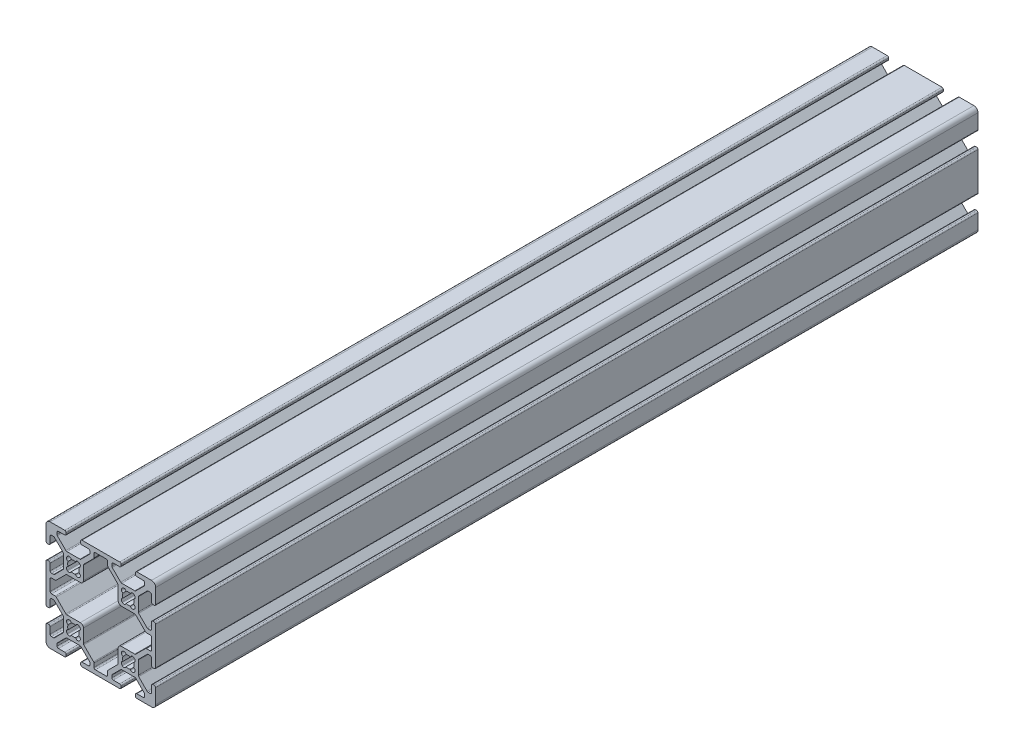
from build123d import *

# Parameters (mm, degrees)
EXTRUDE1_DEPTH = 300


with BuildPart() as part:
    # Sketch1 → Extrude1 (new body)
    with BuildSketch(Plane.XY):
        with BuildLine():
            Line((-22.383919339, -3.655), (-17.616080661, -3.655))
            ThreePointArc((-17.616080661, -3.655), (-17.421677478, -3.693669197), (-17.256870417, -3.803789755))
            Line((-17.256870417, -3.803789755), (-14.153789755, -6.906870417))
            ThreePointArc((-14.153789755, -6.906870417), (-14.043669197, -7.071677478), (-14.005, -7.266080661))
            Line((-14.005, -7.266080661), (-14.005, -7.992))
            ThreePointArc((-14.005, -7.992), (-14.153789755, -8.351210245), (-14.513, -8.5))
            Line((-14.513, -8.5), (-16.862, -8.5))
            ThreePointArc((-16.862, -8.5), (-17.221210245, -8.648789755), (-17.37, -9.008))
            Line((-17.37, -9.008), (-17.37, -9.492))
            ThreePointArc((-17.37, -9.492), (-17.221210245, -9.851210245), (-16.862, -10))
            Line((-16.862, -10), (-3.138, -10))
            ThreePointArc((-3.138, -10), (-2.778789755, -9.851210245), (-2.63, -9.492))
            Line((-2.63, -9.492), (-2.63, -9.008))
            ThreePointArc((-2.63, -9.008), (-2.778789755, -8.648789755), (-3.138, -8.5))
            Line((-3.138, -8.5), (-5.487, -8.5))
            ThreePointArc((-5.487, -8.5), (-5.846210245, -8.351210245), (-5.995, -7.992))
            Line((-5.995, -7.992), (-5.995, -7.266080661))
            ThreePointArc((-5.995, -7.266080661), (-5.956330803, -7.071677478), (-5.846210245, -6.906870417))
            Line((-5.846210245, -6.906870417), (-2.743129583, -3.803789755))
            ThreePointArc((-2.743129583, -3.803789755), (-2.578322522, -3.693669197), (-2.383919339, -3.655))
            Line((-2.383919339, -3.655), (2.383919339, -3.655))
            ThreePointArc((2.383919339, -3.655), (2.578322522, -3.693669197), (2.743129583, -3.803789755))
            Line((2.743129583, -3.803789755), (5.846210245, -6.906870417))
            ThreePointArc((5.846210245, -6.906870417), (5.956330803, -7.071677478), (5.995, -7.266080661))
            Line((5.995, -7.266080661), (5.995, -7.992))
            ThreePointArc((5.995, -7.992), (5.846210245, -8.351210245), (5.487, -8.5))
            Line((5.487, -8.5), (3.138, -8.5))
            ThreePointArc((3.138, -8.5), (2.778789755, -8.648789755), (2.63, -9.008))
            Line((2.63, -9.008), (2.63, -9.492))
            ThreePointArc((2.63, -9.492), (2.778789755, -9.851210245), (3.138, -10))
            Line((3.138, -10), (8.5, -10))
            ThreePointArc((8.5, -10), (9.560660172, -9.560660172), (10, -8.5))
            Line((10, -8.5), (10, -3.138))
            ThreePointArc((10, -3.138), (9.851210245, -2.778789755), (9.492, -2.63))
            Line((9.492, -2.63), (9.008, -2.63))
            ThreePointArc((9.008, -2.63), (8.648789755, -2.778789755), (8.5, -3.138))
            Line((8.5, -3.138), (8.5, -5.487))
            ThreePointArc((8.5, -5.487), (8.351210245, -5.846210245), (7.992, -5.995))
            Line((7.992, -5.995), (7.266080661, -5.995))
            ThreePointArc((7.266080661, -5.995), (7.071677478, -5.956330803), (6.906870417, -5.846210245))
            Line((6.906870417, -5.846210245), (3.803789755, -2.743129583))
            ThreePointArc((3.803789755, -2.743129583), (3.693669197, -2.578322522), (3.655, -2.383919339))
            Line((3.655, -2.383919339), (3.655, 2.383919339))
            ThreePointArc((3.655, 2.383919339), (3.693669197, 2.578322522), (3.803789755, 2.743129583))
            Line((3.803789755, 2.743129583), (6.906870417, 5.846210245))
            ThreePointArc((6.906870417, 5.846210245), (7.071677478, 5.956330803), (7.266080661, 5.995))
            Line((7.266080661, 5.995), (7.992, 5.995))
            ThreePointArc((7.992, 5.995), (8.351210245, 5.846210245), (8.5, 5.487))
            Line((8.5, 5.487), (8.5, 3.138))
            ThreePointArc((8.5, 3.138), (8.648789755, 2.778789755), (9.008, 2.63))
            Line((9.008, 2.63), (9.492, 2.63))
            ThreePointArc((9.492, 2.63), (9.851210245, 2.778789755), (10, 3.138))
            Line((10, 3.138), (10, 16.862))
            ThreePointArc((10, 16.862), (9.851210245, 17.221210245), (9.492, 17.37))
            Line((9.492, 17.37), (9.008, 17.37))
            ThreePointArc((9.008, 17.37), (8.648789755, 17.221210245), (8.5, 16.862))
            Line((8.5, 16.862), (8.5, 14.513))
            ThreePointArc((8.5, 14.513), (8.351210245, 14.153789755), (7.992, 14.005))
            Line((7.992, 14.005), (7.266080661, 14.005))
            ThreePointArc((7.266080661, 14.005), (7.071677478, 14.043669197), (6.906870417, 14.153789755))
            Line((6.906870417, 14.153789755), (3.803789755, 17.256870417))
            ThreePointArc((3.803789755, 17.256870417), (3.693669197, 17.421677478), (3.655, 17.616080661))
            Line((3.655, 17.616080661), (3.655, 22.383919339))
            ThreePointArc((3.655, 22.383919339), (3.693669197, 22.578322522), (3.803789755, 22.743129583))
            Line((3.803789755, 22.743129583), (6.906870417, 25.846210245))
            ThreePointArc((6.906870417, 25.846210245), (7.071677478, 25.956330803), (7.266080661, 25.995))
            Line((7.266080661, 25.995), (7.992, 25.995))
            ThreePointArc((7.992, 25.995), (8.351210245, 25.846210245), (8.5, 25.487))
            Line((8.5, 25.487), (8.5, 23.138))
            ThreePointArc((8.5, 23.138), (8.648789755, 22.778789755), (9.008, 22.63))
            Line((9.008, 22.63), (9.492, 22.63))
            ThreePointArc((9.492, 22.63), (9.851210245, 22.778789755), (10, 23.138))
            Line((10, 23.138), (10, 28.5))
            ThreePointArc((10, 28.5), (9.560660172, 29.560660172), (8.5, 30))
            Line((8.5, 30), (3.138, 30))
            ThreePointArc((3.138, 30), (2.778789755, 29.851210245), (2.63, 29.492))
            Line((2.63, 29.492), (2.63, 29.008))
            ThreePointArc((2.63, 29.008), (2.778789755, 28.648789755), (3.138, 28.5))
            Line((3.138, 28.5), (5.487, 28.5))
            ThreePointArc((5.487, 28.5), (5.846210245, 28.351210245), (5.995, 27.992))
            Line((5.995, 27.992), (5.995, 27.266080661))
            ThreePointArc((5.995, 27.266080661), (5.956330803, 27.071677478), (5.846210245, 26.906870417))
            Line((5.846210245, 26.906870417), (2.743129583, 23.803789755))
            ThreePointArc((2.743129583, 23.803789755), (2.578322522, 23.693669197), (2.383919339, 23.655))
            Line((2.383919339, 23.655), (-2.383919339, 23.655))
            ThreePointArc((-2.383919339, 23.655), (-2.578322522, 23.693669197), (-2.743129583, 23.803789755))
            Line((-2.743129583, 23.803789755), (-5.846210245, 26.906870417))
            ThreePointArc((-5.846210245, 26.906870417), (-5.956330803, 27.071677478), (-5.995, 27.266080661))
            Line((-5.995, 27.266080661), (-5.995, 27.992))
            ThreePointArc((-5.995, 27.992), (-5.846210245, 28.351210245), (-5.487, 28.5))
            Line((-5.487, 28.5), (-3.138, 28.5))
            ThreePointArc((-3.138, 28.5), (-2.778789755, 28.648789755), (-2.63, 29.008))
            Line((-2.63, 29.008), (-2.63, 29.492))
            ThreePointArc((-2.63, 29.492), (-2.778789755, 29.851210245), (-3.138, 30))
            Line((-3.138, 30), (-16.862, 30))
            ThreePointArc((-16.862, 30), (-17.221210245, 29.851210245), (-17.37, 29.492))
            Line((-17.37, 29.492), (-17.37, 29.008))
            ThreePointArc((-17.37, 29.008), (-17.221210245, 28.648789755), (-16.862, 28.5))
            Line((-16.862, 28.5), (-14.513, 28.5))
            ThreePointArc((-14.513, 28.5), (-14.153789755, 28.351210245), (-14.005, 27.992))
            Line((-14.005, 27.992), (-14.005, 27.266080661))
            ThreePointArc((-14.005, 27.266080661), (-14.043669197, 27.071677478), (-14.153789755, 26.906870417))
            Line((-14.153789755, 26.906870417), (-17.256870417, 23.803789755))
            ThreePointArc((-17.256870417, 23.803789755), (-17.421677478, 23.693669197), (-17.616080661, 23.655))
            Line((-17.616080661, 23.655), (-22.383919339, 23.655))
            ThreePointArc((-22.383919339, 23.655), (-22.578322522, 23.693669197), (-22.743129583, 23.803789755))
            Line((-22.743129583, 23.803789755), (-25.846210245, 26.906870417))
            ThreePointArc((-25.846210245, 26.906870417), (-25.956330803, 27.071677478), (-25.995, 27.266080661))
            Line((-25.995, 27.266080661), (-25.995, 27.992))
            ThreePointArc((-25.995, 27.992), (-25.846210245, 28.351210245), (-25.487, 28.5))
            Line((-25.487, 28.5), (-23.138, 28.5))
            ThreePointArc((-23.138, 28.5), (-22.778789755, 28.648789755), (-22.63, 29.008))
            Line((-22.63, 29.008), (-22.63, 29.492))
            ThreePointArc((-22.63, 29.492), (-22.778789755, 29.851210245), (-23.138, 30))
            Line((-23.138, 30), (-28.5, 30))
            ThreePointArc((-28.5, 30), (-29.560660172, 29.560660172), (-30, 28.5))
            Line((-30, 28.5), (-30, 23.138))
            ThreePointArc((-30, 23.138), (-29.851210245, 22.778789755), (-29.492, 22.63))
            Line((-29.492, 22.63), (-29.008, 22.63))
            ThreePointArc((-29.008, 22.63), (-28.648789755, 22.778789755), (-28.5, 23.138))
            Line((-28.5, 23.138), (-28.5, 25.487))
            ThreePointArc((-28.5, 25.487), (-28.351210245, 25.846210245), (-27.992, 25.995))
            Line((-27.992, 25.995), (-27.266080661, 25.995))
            ThreePointArc((-27.266080661, 25.995), (-27.071677478, 25.956330803), (-26.906870417, 25.846210245))
            Line((-26.906870417, 25.846210245), (-23.803789755, 22.743129583))
            ThreePointArc((-23.803789755, 22.743129583), (-23.693669197, 22.578322522), (-23.655, 22.383919339))
            Line((-23.655, 22.383919339), (-23.655, 17.616080661))
            ThreePointArc((-23.655, 17.616080661), (-23.693669197, 17.421677478), (-23.803789755, 17.256870417))
            Line((-23.803789755, 17.256870417), (-26.906870417, 14.153789755))
            ThreePointArc((-26.906870417, 14.153789755), (-27.071677478, 14.043669197), (-27.266080661, 14.005))
            Line((-27.266080661, 14.005), (-27.992, 14.005))
            ThreePointArc((-27.992, 14.005), (-28.351210245, 14.153789755), (-28.5, 14.513))
            Line((-28.5, 14.513), (-28.5, 16.862))
            ThreePointArc((-28.5, 16.862), (-28.648789755, 17.221210245), (-29.008, 17.37))
            Line((-29.008, 17.37), (-29.492, 17.37))
            ThreePointArc((-29.492, 17.37), (-29.851210245, 17.221210245), (-30, 16.862))
            Line((-30, 16.862), (-30, 3.138))
            ThreePointArc((-30, 3.138), (-29.851210245, 2.778789755), (-29.492, 2.63))
            Line((-29.492, 2.63), (-29.008, 2.63))
            ThreePointArc((-29.008, 2.63), (-28.648789755, 2.778789755), (-28.5, 3.138))
            Line((-28.5, 3.138), (-28.5, 5.487))
            ThreePointArc((-28.5, 5.487), (-28.351210245, 5.846210245), (-27.992, 5.995))
            Line((-27.992, 5.995), (-27.266080661, 5.995))
            ThreePointArc((-27.266080661, 5.995), (-27.071677478, 5.956330803), (-26.906870417, 5.846210245))
            Line((-26.906870417, 5.846210245), (-23.803789755, 2.743129583))
            ThreePointArc((-23.803789755, 2.743129583), (-23.693669197, 2.578322522), (-23.655, 2.383919339))
            Line((-23.655, 2.383919339), (-23.655, -2.383919339))
            ThreePointArc((-23.655, -2.383919339), (-23.693669197, -2.578322522), (-23.803789755, -2.743129583))
            Line((-23.803789755, -2.743129583), (-26.906870417, -5.846210245))
            ThreePointArc((-26.906870417, -5.846210245), (-27.071677478, -5.956330803), (-27.266080661, -5.995))
            Line((-27.266080661, -5.995), (-27.992, -5.995))
            ThreePointArc((-27.992, -5.995), (-28.351210245, -5.846210245), (-28.5, -5.487))
            Line((-28.5, -5.487), (-28.5, -3.138))
            ThreePointArc((-28.5, -3.138), (-28.648789755, -2.778789755), (-29.008, -2.63))
            Line((-29.008, -2.63), (-29.492, -2.63))
            ThreePointArc((-29.492, -2.63), (-29.851210245, -2.778789755), (-30, -3.138))
            Line((-30, -3.138), (-30, -8.5))
            ThreePointArc((-30, -8.5), (-29.560660172, -9.560660172), (-28.5, -10))
            Line((-28.5, -10), (-23.138, -10))
            ThreePointArc((-23.138, -10), (-22.778789755, -9.851210245), (-22.63, -9.492))
            Line((-22.63, -9.492), (-22.63, -9.008))
            ThreePointArc((-22.63, -9.008), (-22.778789755, -8.648789755), (-23.138, -8.5))
            Line((-23.138, -8.5), (-25.487, -8.5))
            ThreePointArc((-25.487, -8.5), (-25.846210245, -8.351210245), (-25.995, -7.992))
            Line((-25.995, -7.992), (-25.995, -7.266080661))
            ThreePointArc((-25.995, -7.266080661), (-25.956330803, -7.071677478), (-25.846210245, -6.906870417))
            Line((-25.846210245, -6.906870417), (-22.743129583, -3.803789755))
            ThreePointArc((-22.743129583, -3.803789755), (-22.578322522, -3.693669197), (-22.383919339, -3.655))
        make_face()
        with BuildLine():
            Line((-2.124900844, 17.695494034), (-2.304505966, 17.875099156))
            ThreePointArc((-2.304505966, 17.875099156), (-2.505938017, 18.643532189), (-1.935133506, 19.196023282))
            ThreePointArc((-1.935133506, 19.196023282), (-2.0955, 20), (-1.935133506, 20.803976718))
            ThreePointArc((-1.935133506, 20.803976718), (-2.505938017, 21.356467811), (-2.304505966, 22.124900844))
            Line((-2.304505966, 22.124900844), (-2.124900844, 22.304505966))
            ThreePointArc((-2.124900844, 22.304505966), (-1.356467811, 22.505938017), (-0.803976718, 21.935133506))
            ThreePointArc((-0.803976718, 21.935133506), (0, 22.0955), (0.803976718, 21.935133506))
            ThreePointArc((0.803976718, 21.935133506), (1.356467811, 22.505938017), (2.124900844, 22.304505966))
            Line((2.124900844, 22.304505966), (2.304505966, 22.124900844))
            ThreePointArc((2.304505966, 22.124900844), (2.505938017, 21.356467811), (1.935133506, 20.803976718))
            ThreePointArc((1.935133506, 20.803976718), (2.0955, 20), (1.935133506, 19.196023282))
            ThreePointArc((1.935133506, 19.196023282), (2.505938017, 18.643532189), (2.304505966, 17.875099156))
            Line((2.304505966, 17.875099156), (2.124900844, 17.695494034))
            ThreePointArc((2.124900844, 17.695494034), (1.356467811, 17.494061983), (0.803976718, 18.064866494))
            ThreePointArc((0.803976718, 18.064866494), (0, 17.9045), (-0.803976718, 18.064866494))
            ThreePointArc((-0.803976718, 18.064866494), (-1.356467811, 17.494061983), (-2.124900844, 17.695494034))
        make_face(mode=Mode.SUBTRACT)
        with BuildLine():
            Line((-22.124900844, 17.695494034), (-22.304505966, 17.875099156))
            ThreePointArc((-22.304505966, 17.875099156), (-22.505938017, 18.643532189), (-21.935133506, 19.196023282))
            ThreePointArc((-21.935133506, 19.196023282), (-22.0955, 20), (-21.935133506, 20.803976718))
            ThreePointArc((-21.935133506, 20.803976718), (-22.505938017, 21.356467811), (-22.304505966, 22.124900844))
            Line((-22.304505966, 22.124900844), (-22.124900844, 22.304505966))
            ThreePointArc((-22.124900844, 22.304505966), (-21.356467811, 22.505938017), (-20.803976718, 21.935133506))
            ThreePointArc((-20.803976718, 21.935133506), (-20, 22.0955), (-19.196023282, 21.935133506))
            ThreePointArc((-19.196023282, 21.935133506), (-18.643532189, 22.505938017), (-17.875099156, 22.304505966))
            Line((-17.875099156, 22.304505966), (-17.695494034, 22.124900844))
            ThreePointArc((-17.695494034, 22.124900844), (-17.494061983, 21.356467811), (-18.064866494, 20.803976718))
            ThreePointArc((-18.064866494, 20.803976718), (-17.9045, 20), (-18.064866494, 19.196023282))
            ThreePointArc((-18.064866494, 19.196023282), (-17.494061983, 18.643532189), (-17.695494034, 17.875099156))
            Line((-17.695494034, 17.875099156), (-17.875099156, 17.695494034))
            ThreePointArc((-17.875099156, 17.695494034), (-18.643532189, 17.494061983), (-19.196023282, 18.064866494))
            ThreePointArc((-19.196023282, 18.064866494), (-20, 17.9045), (-20.803976718, 18.064866494))
            ThreePointArc((-20.803976718, 18.064866494), (-21.356467811, 17.494061983), (-22.124900844, 17.695494034))
        make_face(mode=Mode.SUBTRACT)
        with BuildLine():
            Line((-2.124900844, -2.304505966), (-2.304505966, -2.124900844))
            ThreePointArc((-2.304505966, -2.124900844), (-2.505938017, -1.356467811), (-1.935133506, -0.803976718))
            ThreePointArc((-1.935133506, -0.803976718), (-2.0955, 0), (-1.935133506, 0.803976718))
            ThreePointArc((-1.935133506, 0.803976718), (-2.505938017, 1.356467811), (-2.304505966, 2.124900844))
            Line((-2.304505966, 2.124900844), (-2.124900844, 2.304505966))
            ThreePointArc((-2.124900844, 2.304505966), (-1.356467811, 2.505938017), (-0.803976718, 1.935133506))
            ThreePointArc((-0.803976718, 1.935133506), (0, 2.0955), (0.803976718, 1.935133506))
            ThreePointArc((0.803976718, 1.935133506), (1.356467811, 2.505938017), (2.124900844, 2.304505966))
            Line((2.124900844, 2.304505966), (2.304505966, 2.124900844))
            ThreePointArc((2.304505966, 2.124900844), (2.505938017, 1.356467811), (1.935133506, 0.803976718))
            ThreePointArc((1.935133506, 0.803976718), (2.0955, 0), (1.935133506, -0.803976718))
            ThreePointArc((1.935133506, -0.803976718), (2.505938017, -1.356467811), (2.304505966, -2.124900844))
            Line((2.304505966, -2.124900844), (2.124900844, -2.304505966))
            ThreePointArc((2.124900844, -2.304505966), (1.356467811, -2.505938017), (0.803976718, -1.935133506))
            ThreePointArc((0.803976718, -1.935133506), (0, -2.0955), (-0.803976718, -1.935133506))
            ThreePointArc((-0.803976718, -1.935133506), (-1.356467811, -2.505938017), (-2.124900844, -2.304505966))
        make_face(mode=Mode.SUBTRACT)
        with BuildLine():
            Line((-12.505, -7.992), (-12.505, -6.644760318))
            ThreePointArc((-12.505, -6.644760318), (-12.543669197, -6.450357134), (-12.653789755, -6.285550073))
            Line((-12.653789755, -6.285550073), (-16.196210245, -2.743129583))
            ThreePointArc((-16.196210245, -2.743129583), (-16.306330803, -2.578322522), (-16.345, -2.383919339))
            Line((-16.345, -2.383919339), (-16.345, 2.512))
            ThreePointArc((-16.345, 2.512), (-16.679776949, 3.320223051), (-17.488, 3.655))
            Line((-17.488, 3.655), (-22.383919339, 3.655))
            ThreePointArc((-22.383919339, 3.655), (-22.578322522, 3.693669197), (-22.743129583, 3.803789755))
            Line((-22.743129583, 3.803789755), (-26.285550073, 7.346210245))
            ThreePointArc((-26.285550073, 7.346210245), (-26.450357134, 7.456330803), (-26.644760318, 7.495))
            Line((-26.644760318, 7.495), (-27.992, 7.495))
            ThreePointArc((-27.992, 7.495), (-28.351210245, 7.643789755), (-28.5, 8.003))
            Line((-28.5, 8.003), (-28.5, 11.997))
            ThreePointArc((-28.5, 11.997), (-28.351210245, 12.356210245), (-27.992, 12.505))
            Line((-27.992, 12.505), (-26.644760318, 12.505))
            ThreePointArc((-26.644760318, 12.505), (-26.450357134, 12.543669197), (-26.285550073, 12.653789755))
            Line((-26.285550073, 12.653789755), (-22.743129583, 16.196210245))
            ThreePointArc((-22.743129583, 16.196210245), (-22.578322522, 16.306330803), (-22.383919339, 16.345))
            Line((-22.383919339, 16.345), (-17.488, 16.345))
            ThreePointArc((-17.488, 16.345), (-16.679776949, 16.679776949), (-16.345, 17.488))
            Line((-16.345, 17.488), (-16.345, 22.383919339))
            ThreePointArc((-16.345, 22.383919339), (-16.306330803, 22.578322522), (-16.196210245, 22.743129583))
            Line((-16.196210245, 22.743129583), (-12.653789755, 26.285550073))
            ThreePointArc((-12.653789755, 26.285550073), (-12.543669197, 26.450357134), (-12.505, 26.644760318))
            Line((-12.505, 26.644760318), (-12.505, 27.992))
            ThreePointArc((-12.505, 27.992), (-12.356210245, 28.351210245), (-11.997, 28.5))
            Line((-11.997, 28.5), (-8.003, 28.5))
            ThreePointArc((-8.003, 28.5), (-7.643789755, 28.351210245), (-7.495, 27.992))
            Line((-7.495, 27.992), (-7.495, 26.644760318))
            ThreePointArc((-7.495, 26.644760318), (-7.456330803, 26.450357134), (-7.346210245, 26.285550073))
            Line((-7.346210245, 26.285550073), (-3.803789755, 22.743129583))
            ThreePointArc((-3.803789755, 22.743129583), (-3.693669197, 22.578322522), (-3.655, 22.383919339))
            Line((-3.655, 22.383919339), (-3.655, 17.488))
            ThreePointArc((-3.655, 17.488), (-3.320223051, 16.679776949), (-2.512, 16.345))
            Line((-2.512, 16.345), (2.383919339, 16.345))
            ThreePointArc((2.383919339, 16.345), (2.578322522, 16.306330803), (2.743129583, 16.196210245))
            Line((2.743129583, 16.196210245), (6.285550073, 12.653789755))
            ThreePointArc((6.285550073, 12.653789755), (6.450357134, 12.543669197), (6.644760318, 12.505))
            Line((6.644760318, 12.505), (7.992, 12.505))
            ThreePointArc((7.992, 12.505), (8.351210245, 12.356210245), (8.5, 11.997))
            Line((8.5, 11.997), (8.5, 8.003))
            ThreePointArc((8.5, 8.003), (8.351210245, 7.643789755), (7.992, 7.495))
            Line((7.992, 7.495), (6.644760318, 7.495))
            ThreePointArc((6.644760318, 7.495), (6.450357134, 7.456330803), (6.285550073, 7.346210245))
            Line((6.285550073, 7.346210245), (2.743129583, 3.803789755))
            ThreePointArc((2.743129583, 3.803789755), (2.578322522, 3.693669197), (2.383919339, 3.655))
            Line((2.383919339, 3.655), (-2.512, 3.655))
            ThreePointArc((-2.512, 3.655), (-3.320223051, 3.320223051), (-3.655, 2.512))
            Line((-3.655, 2.512), (-3.655, -2.383919339))
            ThreePointArc((-3.655, -2.383919339), (-3.693669197, -2.578322522), (-3.803789755, -2.743129583))
            Line((-3.803789755, -2.743129583), (-7.346210245, -6.285550073))
            ThreePointArc((-7.346210245, -6.285550073), (-7.456330803, -6.450357134), (-7.495, -6.644760318))
            Line((-7.495, -6.644760318), (-7.495, -7.992))
            ThreePointArc((-7.495, -7.992), (-7.643789755, -8.351210245), (-8.003, -8.5))
            Line((-8.003, -8.5), (-11.997, -8.5))
            ThreePointArc((-11.997, -8.5), (-12.356210245, -8.351210245), (-12.505, -7.992))
        make_face(mode=Mode.SUBTRACT)
        with BuildLine():
            Line((-22.124900844, -2.304505966), (-22.304505966, -2.124900844))
            ThreePointArc((-22.304505966, -2.124900844), (-22.505938017, -1.356467811), (-21.935133506, -0.803976718))
            ThreePointArc((-21.935133506, -0.803976718), (-22.0955, 0), (-21.935133506, 0.803976718))
            ThreePointArc((-21.935133506, 0.803976718), (-22.505938017, 1.356467811), (-22.304505966, 2.124900844))
            Line((-22.304505966, 2.124900844), (-22.124900844, 2.304505966))
            ThreePointArc((-22.124900844, 2.304505966), (-21.356467811, 2.505938017), (-20.803976718, 1.935133506))
            ThreePointArc((-20.803976718, 1.935133506), (-20, 2.0955), (-19.196023282, 1.935133506))
            ThreePointArc((-19.196023282, 1.935133506), (-18.643532189, 2.505938017), (-17.875099156, 2.304505966))
            Line((-17.875099156, 2.304505966), (-17.695494034, 2.124900844))
            ThreePointArc((-17.695494034, 2.124900844), (-17.494061983, 1.356467811), (-18.064866494, 0.803976718))
            ThreePointArc((-18.064866494, 0.803976718), (-17.9045, 0), (-18.064866494, -0.803976718))
            ThreePointArc((-18.064866494, -0.803976718), (-17.494061983, -1.356467811), (-17.695494034, -2.124900844))
            Line((-17.695494034, -2.124900844), (-17.875099156, -2.304505966))
            ThreePointArc((-17.875099156, -2.304505966), (-18.643532189, -2.505938017), (-19.196023282, -1.935133506))
            ThreePointArc((-19.196023282, -1.935133506), (-20, -2.0955), (-20.803976718, -1.935133506))
            ThreePointArc((-20.803976718, -1.935133506), (-21.356467811, -2.505938017), (-22.124900844, -2.304505966))
        make_face(mode=Mode.SUBTRACT)
    extrude(amount=-EXTRUDE1_DEPTH)


solid = part.part
